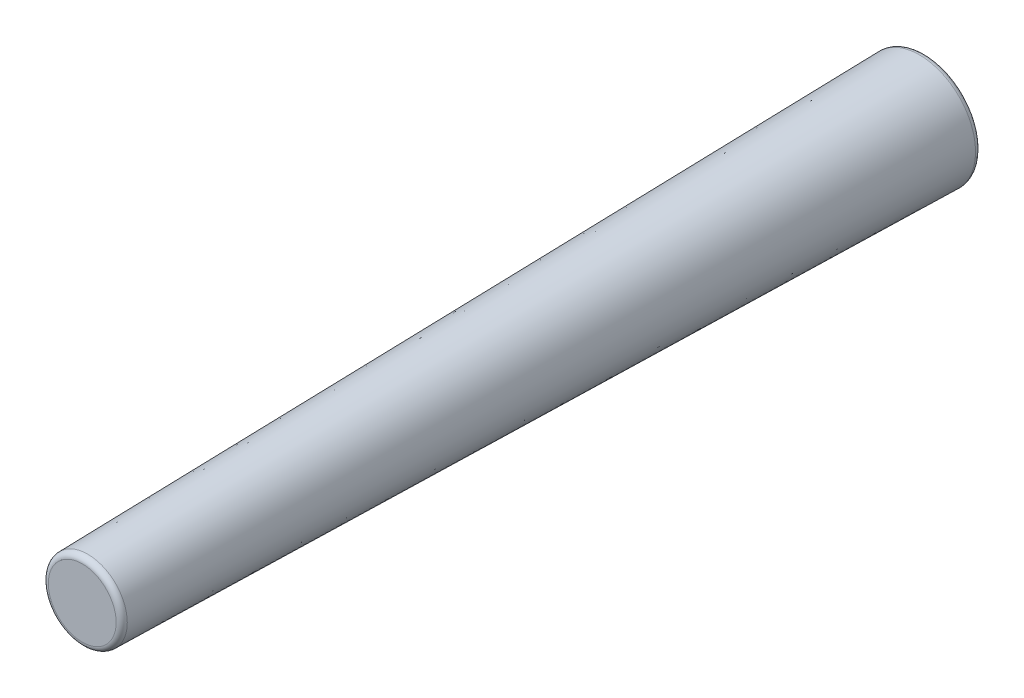
from build123d import *

# Parameters (mm, degrees)
SKETCH_1_R      = 1
EXTRUDE_1_DEPTH = 15
EXTRUDE_1_TAPER = 1.14
FILLET_1_R      = 0.1


with BuildPart() as part:
    # 草图1 → 凸台-拉伸1 (new body)
    with BuildSketch(Plane.XY):
        Circle(SKETCH_1_R)
    extrude(amount=EXTRUDE_1_DEPTH, taper=EXTRUDE_1_TAPER)

    # 圆角1
    fillet_1_edges = [part.edges().sort_by_distance(p)[0] for p in [
        (-1, 0, 0),
        (-0.701509308, 0, 15),
    ]]
    fillet(fillet_1_edges, radius=FILLET_1_R)


solid = part.part
